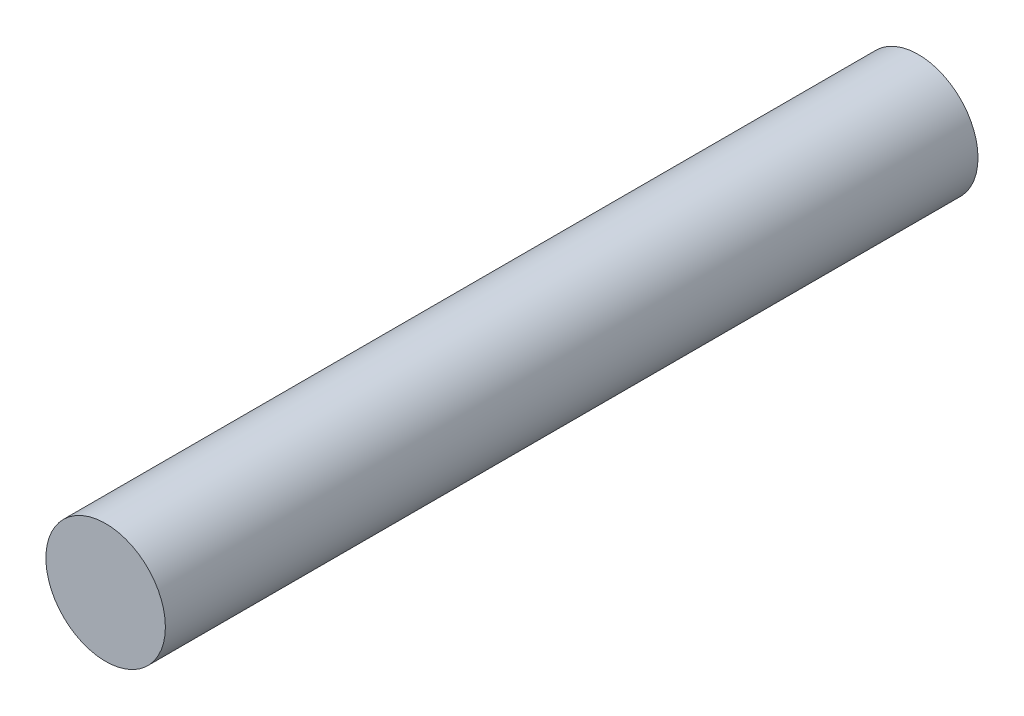
from build123d import *

# Parameters (mm, degrees)
SKETCH1_R           = 1.25
BOSS_EXTRUDE1_DEPTH = 17


with BuildPart() as part:
    # Sketch1 → Boss-Extrude1 (new body)
    with BuildSketch(Plane.XY):
        Circle(SKETCH1_R)
    extrude(amount=BOSS_EXTRUDE1_DEPTH)


solid = part.part
